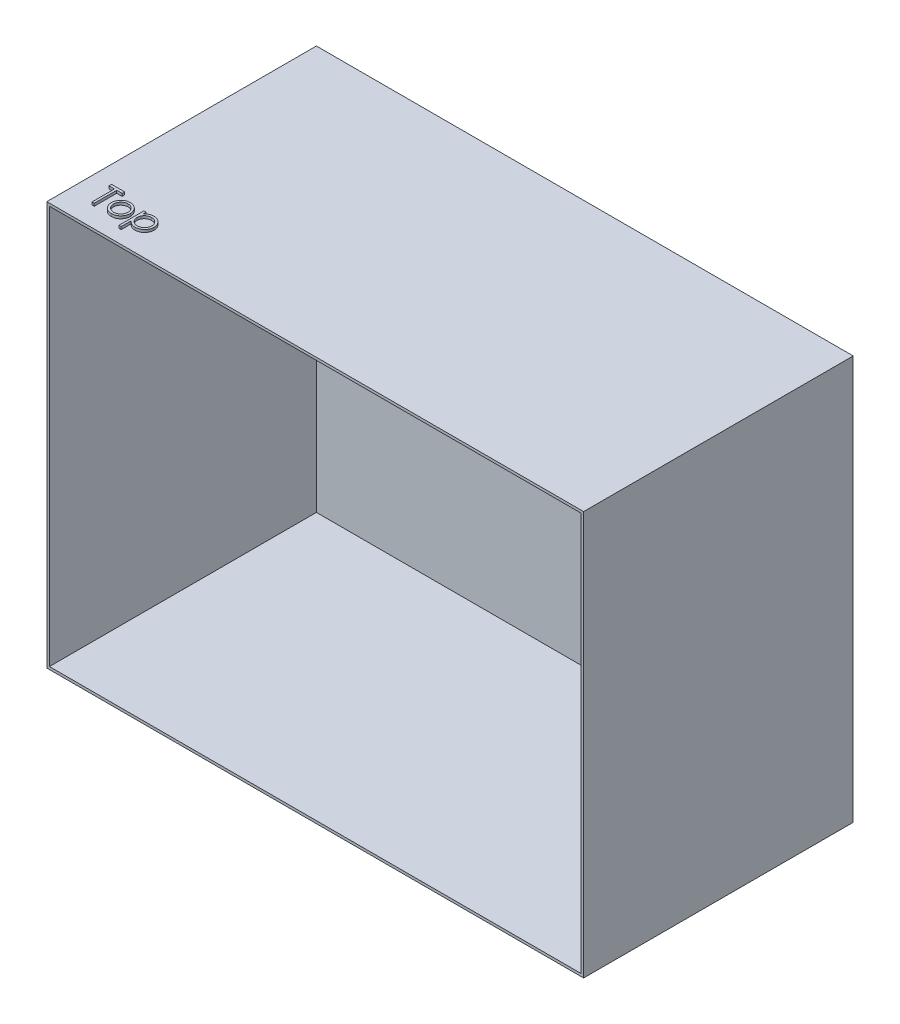
from build123d import *

# Parameters (mm, degrees)
SKETCH1_W           = 408.64
SKETCH1_H           = 307.48
BOSS_EXTRUDE1_DEPTH = 2
SKETCH1_6_W         = 408.64
SKETCH1_6_H         = 307.48
SKETCH1_6_W_2       = 404.64
SKETCH1_6_H_2       = 303.48
BOSS_EXTRUDE4_DEPTH = 203.2
BOSS_EXTRUDE5_DEPTH = 2


with BuildPart() as part:
    # Sketch1 → Boss-Extrude1 (new body)
    with BuildSketch(Plane.XY):
        Rectangle(SKETCH1_W, SKETCH1_H)
    extrude(amount=-BOSS_EXTRUDE1_DEPTH)

    # Sketch1_6 → Boss-Extrude4 (add)
    with BuildSketch(Plane.XY):
        Rectangle(SKETCH1_6_W, SKETCH1_6_H)
        Rectangle(SKETCH1_6_W_2, SKETCH1_6_H_2, mode=Mode.SUBTRACT)
    extrude(amount=BOSS_EXTRUDE4_DEPTH)

    # Sketch4 → Boss-Extrude5 (add)
    # profile 1 of 3: a face of its own
    with BuildSketch(Plane(origin=(0, 153.74, 0), x_dir=(1, 0, 0), z_dir=(0, 1, 0))):
        Polygon((-189.075769231, -171.103846154), (-189.075769231, -169.15), (-179.062307692, -169.15), (-179.062307692, -171.103846154), (-183.214230769, -171.103846154), (-183.214230769, -188.2), (-184.923846154, -188.2), (-184.923846154, -171.103846154), align=None)
    # profile 2 of 3: a face of its own
    with BuildSketch(Plane(origin=(0, 153.74, 0), x_dir=(1, 0, 0), z_dir=(0, 1, 0))):
        with BuildLine():
            add(Edge.make_bspline(
                [(-169.896021635, -174.034615385), (-169.634811992, -174.040177392), (-169.122643721, -174.051083129), (-168.372575085, -174.167641728), (-167.656593702, -174.345880954), (-166.971957427, -174.592287599), (-166.327434448, -174.922570787), (-165.713636676, -175.316684215), (-165.132246956, -175.783586617), (-164.783778754, -176.144764103), (-164.606899038, -176.328094952)],
                knots=[0, 0, 0, 0, 1.054011418, 2.066658804, 3.057071809, 4.030435133, 4.997543892, 5.974964718, 6.972108034, 8, 8, 8, 8], degree=3))
            add(Edge.make_bspline(
                [(-164.606899038, -176.328094952), (-164.45459726, -176.503431075), (-164.152941162, -176.850710083), (-163.766140607, -177.413804205), (-163.432920401, -177.996952467), (-163.165877713, -178.60789863), (-162.955320655, -179.241309341), (-162.805828794, -179.899361716), (-162.716909191, -180.580602491), (-162.704918757, -181.043266238), (-162.698846154, -181.277584135)],
                knots=[0, 0, 0, 0, 1.025258237, 2.030674902, 3.01204498, 3.988269485, 4.97094183, 5.956517959, 6.965070386, 8, 8, 8, 8], degree=3))
            add(Edge.make_bspline(
                [(-162.698846154, -181.277584135), (-162.704187433, -181.513260163), (-162.714742049, -181.978966986), (-162.814583732, -182.664872391), (-162.969874357, -183.329961354), (-163.192116219, -183.971449387), (-163.477093928, -184.591297348), (-163.824841813, -185.186797895), (-164.237800186, -185.759125935), (-164.705907654, -186.303421654), (-165.223261437, -186.805069195), (-165.784507902, -187.24228449), (-166.378617714, -187.616870216), (-167.013490823, -187.918602707), (-167.683329572, -188.156508361), (-168.389578757, -188.323604165), (-169.131141211, -188.424632758), (-169.637475088, -188.437606207), (-169.896021635, -188.444230769)],
                knots=[0, 0, 0, 0, 0.998656419, 1.973391657, 2.932242238, 3.890759089, 4.846373663, 5.82037756, 6.809684879, 7.83454468, 8.860553229, 9.859544525, 10.845671541, 11.83227036, 12.833544569, 13.85385346, 14.904124723, 16, 16, 16, 16], degree=3))
            add(Edge.make_bspline(
                [(-169.896021635, -188.444230769), (-170.155834894, -188.437583973), (-170.664692287, -188.424565886), (-171.408872275, -188.323996676), (-172.116387201, -188.15658537), (-172.787102858, -187.917820874), (-173.424705525, -187.616860572), (-174.022257744, -187.243416947), (-174.583960142, -186.804939531), (-175.101423371, -186.303456788), (-175.569501494, -185.759116883), (-175.98246744, -185.186800244), (-176.330213358, -184.591296736), (-176.615191582, -183.971449551), (-176.837433306, -183.329961311), (-176.992723968, -182.664872403), (-177.092565642, -181.978966983), (-177.103120259, -181.513260162), (-177.108461538, -181.277584135)],
                knots=[0, 0, 0, 0, 1.099876186, 2.154163076, 3.173186993, 4.173200201, 5.163417411, 6.152872554, 7.150605724, 8.17532212, 9.198891216, 10.186952605, 11.159729845, 12.11414092, 13.071450619, 14.029093627, 15.002601286, 16, 16, 16, 16], degree=3))
            add(Edge.make_bspline(
                [(-177.108461538, -181.277584135), (-177.102347521, -181.044539792), (-177.090242816, -180.583152045), (-177.001412617, -179.9031919), (-176.852503902, -179.246253254), (-176.641694444, -178.615287449), (-176.372190334, -178.007018576), (-176.043652467, -177.422429424), (-175.65290631, -176.861881539), (-175.352449973, -176.51505136), (-175.200408654, -176.339543269)],
                knots=[0, 0, 0, 0, 1.031353054, 2.041901799, 3.029428768, 4.008703097, 4.981709435, 5.96992636, 6.972712378, 8, 8, 8, 8], degree=3))
            add(Edge.make_bspline(
                [(-175.200408654, -176.339543269), (-175.023795608, -176.154622528), (-174.676454978, -175.790943353), (-174.092171189, -175.325402044), (-173.479883391, -174.923087413), (-172.828237721, -174.599366869), (-172.14416388, -174.344431508), (-171.424513432, -174.167182062), (-170.671899555, -174.051503087), (-170.157225045, -174.040300719), (-169.896021635, -174.034615385)],
                knots=[0, 0, 0, 0, 1.027980169, 2.021703884, 2.998553061, 3.971491411, 4.943284454, 5.930300938, 6.949603206, 8, 8, 8, 8], degree=3))
        make_face()
        with BuildLine():
            add(Edge.make_bspline(
                [(-169.903653846, -175.744230769), (-170.088371416, -175.749480904), (-170.453038102, -175.759845642), (-170.989810413, -175.838679466), (-171.506556108, -175.963579453), (-172.00425556, -176.141038673), (-172.481230398, -176.370176966), (-172.937937289, -176.651618183), (-173.375719569, -176.981634704), (-173.786013371, -177.359710102), (-174.162562813, -177.772708629), (-174.4917358, -178.212754697), (-174.771635307, -178.672710667), (-175.004808172, -179.153054845), (-175.178474439, -179.658654984), (-175.30460189, -180.183785277), (-175.383361341, -180.729515615), (-175.393628631, -181.1005063), (-175.398846154, -181.289032452)],
                knots=[0, 0, 0, 0, 1.021534396, 2.016698045, 2.994645724, 3.958388632, 4.93408049, 5.916473867, 6.921342795, 7.962252576, 8.998418191, 10.008913653, 10.997312074, 11.973003931, 12.956656626, 13.948281152, 14.957379055, 16, 16, 16, 16], degree=3))
            add(Edge.make_bspline(
                [(-175.398846154, -181.289032452), (-175.390100442, -181.532611343), (-175.37274184, -182.016069893), (-175.231580054, -182.728056146), (-174.99543473, -183.411580227), (-174.676552536, -184.062635128), (-174.277012975, -184.665008527), (-173.806276226, -185.20206332), (-173.269394428, -185.665717523), (-172.672767477, -186.050423268), (-172.028581833, -186.356092795), (-171.346829571, -186.572712934), (-170.635770936, -186.71352886), (-170.149828671, -186.727525028), (-169.903653846, -186.734615385)],
                knots=[0, 0, 0, 0, 1.016792936, 2.018143844, 3.017858371, 4.030088057, 5.03801393, 6.028138512, 7.003788237, 7.991172063, 8.984598303, 9.972568034, 10.972917682, 12, 12, 12, 12], degree=3))
            add(Edge.make_bspline(
                [(-169.903653846, -186.734615385), (-169.657493181, -186.727483716), (-169.171578866, -186.713406001), (-168.461508203, -186.57342214), (-167.781619299, -186.355143643), (-167.138102747, -186.050767044), (-166.541747377, -185.664256615), (-166.001004302, -185.204681477), (-165.534286862, -184.663586086), (-165.135142527, -184.061837251), (-164.811038113, -183.412589563), (-164.575998114, -182.727929992), (-164.434496968, -182.016102021), (-164.417184172, -181.532622107), (-164.408461538, -181.289032452)],
                knots=[0, 0, 0, 0, 1.02726834, 2.027799167, 3.010890988, 4.004497153, 4.992059811, 5.971914811, 6.958719428, 7.966827853, 8.981595046, 9.981490638, 10.983022906, 12, 12, 12, 12], degree=3))
            add(Edge.make_bspline(
                [(-164.408461538, -181.289032452), (-164.413677265, -181.100505174), (-164.42394102, -180.729512271), (-164.502726183, -180.183798059), (-164.628758477, -179.658608083), (-164.802775423, -179.153227894), (-165.034935127, -178.671466978), (-165.320232243, -178.214105178), (-165.64806111, -177.771184263), (-166.029154297, -177.361045161), (-166.439019825, -176.981487319), (-166.876979533, -176.651490214), (-167.333009202, -176.371413872), (-167.808598345, -176.139078763), (-168.306361606, -175.965193953), (-168.822383266, -175.837958288), (-169.35686536, -175.760178789), (-169.720225295, -175.749580776), (-169.903653846, -175.744230769)],
                knots=[0, 0, 0, 0, 1.042956736, 2.052379634, 3.044323526, 4.02829302, 5.004299113, 5.996692471, 7.007513377, 8.048758398, 9.090003419, 10.095195979, 11.07790575, 12.047570684, 13.018257071, 13.989683339, 14.985167495, 16, 16, 16, 16], degree=3))
        make_face(mode=Mode.SUBTRACT)
    # profile 3 of 3: a face of its own
    with BuildSketch(Plane(origin=(0, 153.74, 0), x_dir=(1, 0, 0), z_dir=(0, 1, 0))):
        with BuildLine():
            Line((-159.279615385, -174.278846154), (-157.57, -174.278846154))
            Line((-157.57, -174.278846154), (-157.57, -176.854717548))
            add(Edge.make_bspline(
                [(-157.57, -176.854717548), (-157.38843998, -176.621013597), (-157.035614414, -176.166856737), (-156.427511718, -175.579081894), (-155.785652944, -175.083372027), (-155.093520655, -174.694847098), (-154.361871714, -174.401908107), (-153.593708672, -174.185394244), (-152.782511966, -174.057805647), (-152.227904131, -174.042447748), (-151.945060096, -174.034615385)],
                knots=[0, 0, 0, 0, 1.0828784, 2.104357462, 3.088488658, 4.04616522, 5.001424249, 5.969181776, 6.964304535, 8, 8, 8, 8], degree=3))
            add(Edge.make_bspline(
                [(-151.945060096, -174.034615385), (-151.698000084, -174.04176283), (-151.209672992, -174.05589013), (-150.490871704, -174.151537756), (-149.798674259, -174.315464053), (-149.136996708, -174.551689036), (-148.498750596, -174.843728093), (-147.893384596, -175.212302244), (-147.311469386, -175.63905594), (-146.767639842, -176.130176646), (-146.265147827, -176.661553354), (-145.83055647, -177.233174752), (-145.455696534, -177.826242544), (-145.152691063, -178.449950931), (-144.915337058, -179.099388454), (-144.746528598, -179.777178968), (-144.646066281, -180.480809444), (-144.632587309, -180.959251394), (-144.625769231, -181.201262019)],
                knots=[0, 0, 0, 0, 1.041296284, 2.058176809, 3.050446431, 4.034000596, 5.01514041, 6.003636468, 7.015969324, 8.052561599, 9.08815499, 10.094063707, 11.074456064, 12.040834395, 13.011057502, 13.983766392, 14.980127149, 16, 16, 16, 16], degree=3))
            add(Edge.make_bspline(
                [(-144.625769231, -181.201262019), (-144.632439374, -181.448380299), (-144.645593858, -181.935733207), (-144.747620247, -182.651398694), (-144.910671234, -183.3398514), (-145.145030773, -183.99994622), (-145.447879446, -184.631228665), (-145.816385696, -185.233243478), (-146.251196324, -185.805797776), (-146.748135319, -186.341118561), (-147.287266299, -186.834237679), (-147.863542349, -187.265519172), (-148.468020215, -187.627694372), (-149.097607297, -187.93022448), (-149.757693272, -188.158237653), (-150.445198398, -188.322708825), (-151.159748366, -188.424133724), (-151.645801779, -188.437480385), (-151.891634615, -188.444230769)],
                knots=[0, 0, 0, 0, 1.038740735, 2.04854663, 3.033179607, 4.009277356, 4.987731542, 5.972001279, 6.972200261, 8.005528982, 9.039189865, 10.040446548, 11.026516639, 11.997840187, 12.972163198, 13.956796175, 14.96660207, 16, 16, 16, 16], degree=3))
            add(Edge.make_bspline(
                [(-151.891634615, -188.444230769), (-152.168281828, -188.437183316), (-152.714741181, -188.423262529), (-153.51373993, -188.282186883), (-154.282689652, -188.071347276), (-155.013071141, -187.762742754), (-155.710670235, -187.369466303), (-156.371540892, -186.889895039), (-156.999193504, -186.325031924), (-157.376975455, -185.896505896), (-157.57, -185.677554087)],
                knots=[0, 0, 0, 0, 1.014726462, 2.004382257, 2.969841629, 3.936926163, 4.907207904, 5.903978561, 6.929055279, 8, 8, 8, 8], degree=3))
            Line((-157.57, -185.677554087), (-157.57, -193.328846154))
            Line((-157.57, -193.328846154), (-159.279615385, -193.328846154))
            Line((-159.279615385, -193.328846154), (-159.279615385, -174.278846154))
        make_face()
        with BuildLine():
            add(Edge.make_bspline(
                [(-151.960324519, -175.744230769), (-152.153978995, -175.747715603), (-152.535234743, -175.754576343), (-153.094064963, -175.836077407), (-153.632338649, -175.954392827), (-154.144630984, -176.133527598), (-154.635852197, -176.353412567), (-155.102218865, -176.628178943), (-155.543403625, -176.952856289), (-155.958296462, -177.321225289), (-156.333109531, -177.727124663), (-156.664922039, -178.160309738), (-156.943636085, -178.620231927), (-157.17496851, -179.102607114), (-157.351008377, -179.611216452), (-157.47595308, -180.143163278), (-157.554495429, -180.699029827), (-157.564776645, -181.077613234), (-157.57, -181.269951923)],
                knots=[0, 0, 0, 0, 1.05670511, 2.080379991, 3.077984906, 4.06214886, 5.038337365, 6.01289324, 7.01187578, 8.025460281, 9.038092164, 10.024533457, 11.000252242, 11.969694649, 12.940728589, 13.933144304, 14.949937299, 16, 16, 16, 16], degree=3))
            add(Edge.make_bspline(
                [(-157.57, -181.269951923), (-157.561341198, -181.522435793), (-157.54437787, -182.017073077), (-157.406470196, -182.739798083), (-157.182032544, -183.423702094), (-156.863469117, -184.063025738), (-156.460983034, -184.650760884), (-155.976034497, -185.177034042), (-155.41301147, -185.638537116), (-154.781274326, -186.027272797), (-154.104062444, -186.342893558), (-153.397656265, -186.568849475), (-152.671770271, -186.708035461), (-152.180996988, -186.725707433), (-151.933611779, -186.734615385)],
                knots=[0, 0, 0, 0, 1.03728447, 2.032128127, 3.01272805, 3.987917167, 4.958271349, 5.931593992, 6.91984656, 7.941419022, 8.973179163, 9.983609215, 10.983593296, 12, 12, 12, 12], degree=3))
            add(Edge.make_bspline(
                [(-151.933611779, -186.734615385), (-151.691209956, -186.726144248), (-151.210085916, -186.709330564), (-150.501653855, -186.563798428), (-149.81318338, -186.341484795), (-149.15905987, -186.017310637), (-148.544977743, -185.620036179), (-147.990451002, -185.143459427), (-147.505999087, -184.591064164), (-147.09308024, -183.975975027), (-146.760350298, -183.316434725), (-146.510358564, -182.634001738), (-146.366076187, -181.93108165), (-146.345628523, -181.457565527), (-146.335384615, -181.220342548)],
                knots=[0, 0, 0, 0, 1.00104056, 1.986885549, 2.97790532, 3.984399681, 4.995088187, 5.994304198, 6.996462723, 8.023150851, 9.048424203, 10.043036403, 11.019596776, 12, 12, 12, 12], degree=3))
            add(Edge.make_bspline(
                [(-146.335384615, -181.220342548), (-146.343302524, -180.981646107), (-146.359076652, -180.506112912), (-146.5144541, -179.805274825), (-146.74795255, -179.120084556), (-147.088452533, -178.469551278), (-147.492319443, -177.855738056), (-147.980799526, -177.313880515), (-148.52843911, -176.839422996), (-149.141790131, -176.447453408), (-149.800051589, -176.135656643), (-150.493008489, -175.90768998), (-151.21714581, -175.770672858), (-151.710419187, -175.75312233), (-151.960324519, -175.744230769)],
                knots=[0, 0, 0, 0, 0.983928682, 1.960191568, 2.949917689, 3.96440592, 4.982380491, 5.975291189, 6.965713506, 7.964880129, 8.970154049, 9.96478489, 10.968906225, 12, 12, 12, 12], degree=3))
        make_face(mode=Mode.SUBTRACT)
    extrude(amount=BOSS_EXTRUDE5_DEPTH)


solid = part.part
